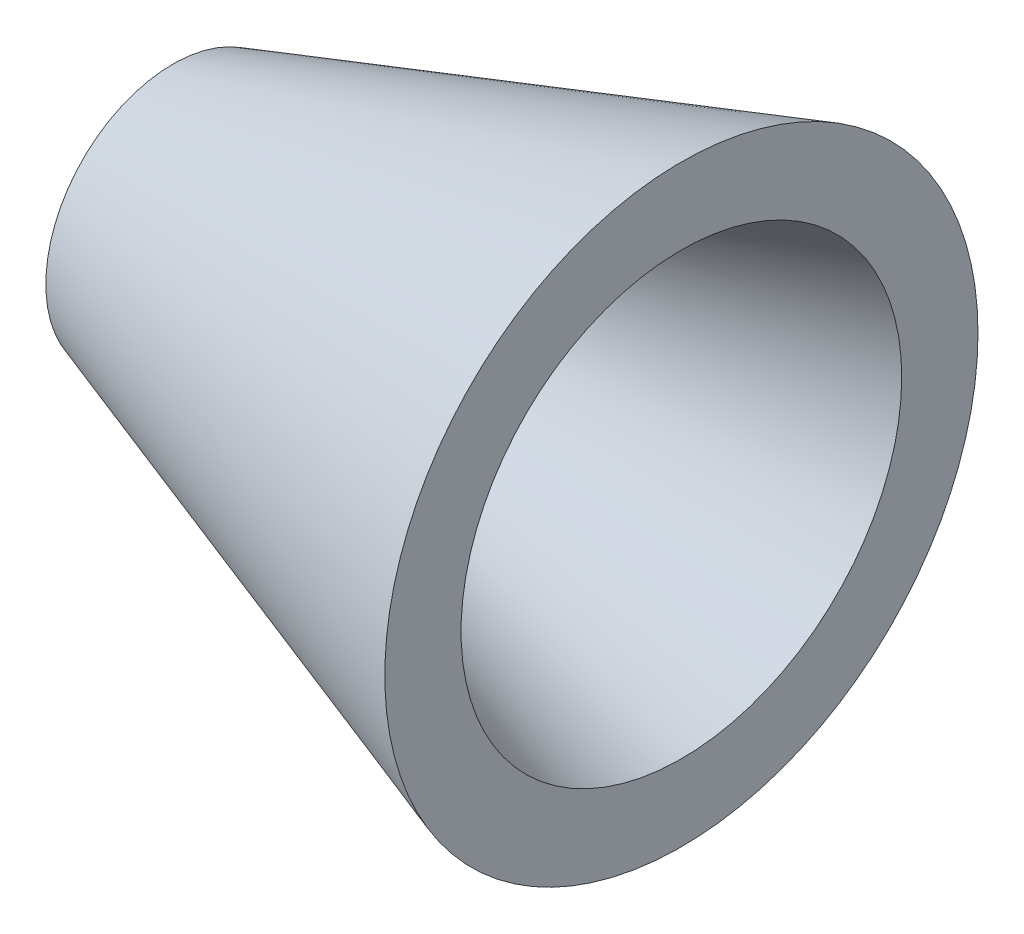
from build123d import *


with BuildPart() as part:
    # Sketch1 → Revolve1 (revolve)
    with BuildSketch(Plane.XY):
        Polygon((-140, 0), (-200, 0), (-200, 100), (200, 233.333333333), (200, 173.333333333), (-140, 60), align=None)
    revolve(axis=Axis((-140, 0, 0), (-1, 0, 0)))


solid = part.part
